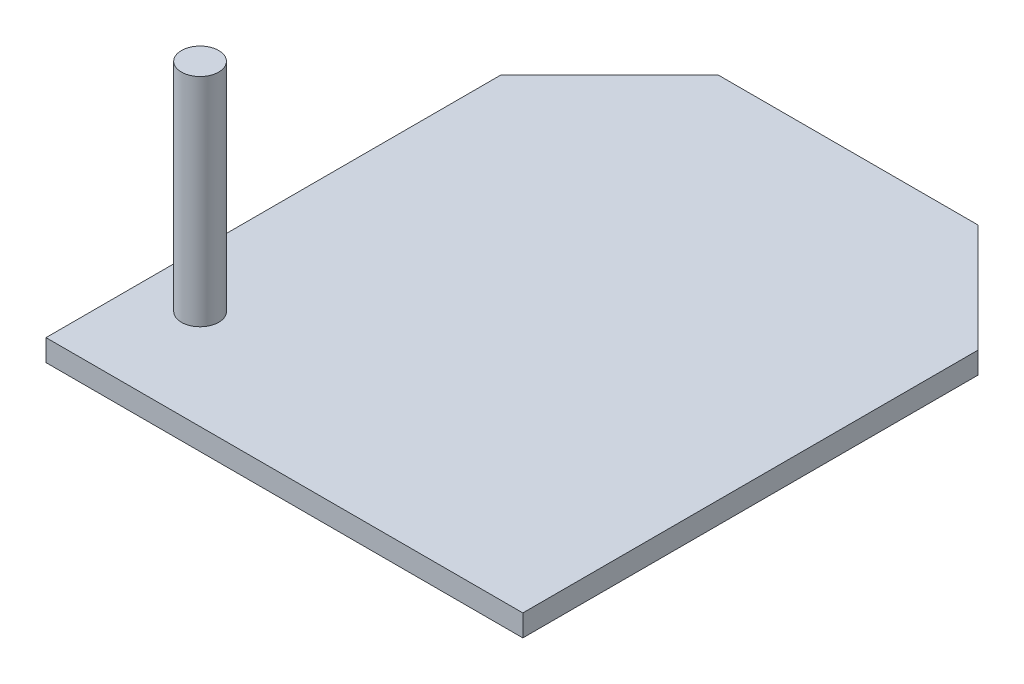
from build123d import *

# Parameters (mm, degrees)
SKETCH1_W      = 22
SKETCH1_H      = 26
EXTRUDE1_DEPTH = 1
CHAMFER1_SIZE  = 5
SKETCH2_R      = 0.861123247
EXTRUDE2_DEPTH = 10


with BuildPart() as part:
    # Sketch1 → Extrude1 (new body)
    with BuildSketch(Plane(origin=(0, 0, 0), x_dir=(1, 0, 0), z_dir=(0, 1, 0))):
        with Locations((1.510761589, -2.012913907)):
            Rectangle(SKETCH1_W, SKETCH1_H)
    extrude(amount=EXTRUDE1_DEPTH)

    # Chamfer1
    chamfer1_edges = [part.edges().sort_by_distance(p)[0] for p in [
        (-9.489238411, 0.5, -10.987086093),
        (12.510761589, 0.5, -10.987086093),
    ]]
    chamfer(chamfer1_edges, length=CHAMFER1_SIZE)

    # Sketch2 → Extrude2 (add)
    with BuildSketch(Plane(origin=(0, 1, 0), x_dir=(1, 0, 0), z_dir=(0, 1, 0))):
        with Locations(Location((-6.975728575, -10.417730268, 0), (0, 0, 90))):  # turned: the seam where the file's is
            Circle(SKETCH2_R)
    extrude(amount=EXTRUDE2_DEPTH)


solid = part.part
